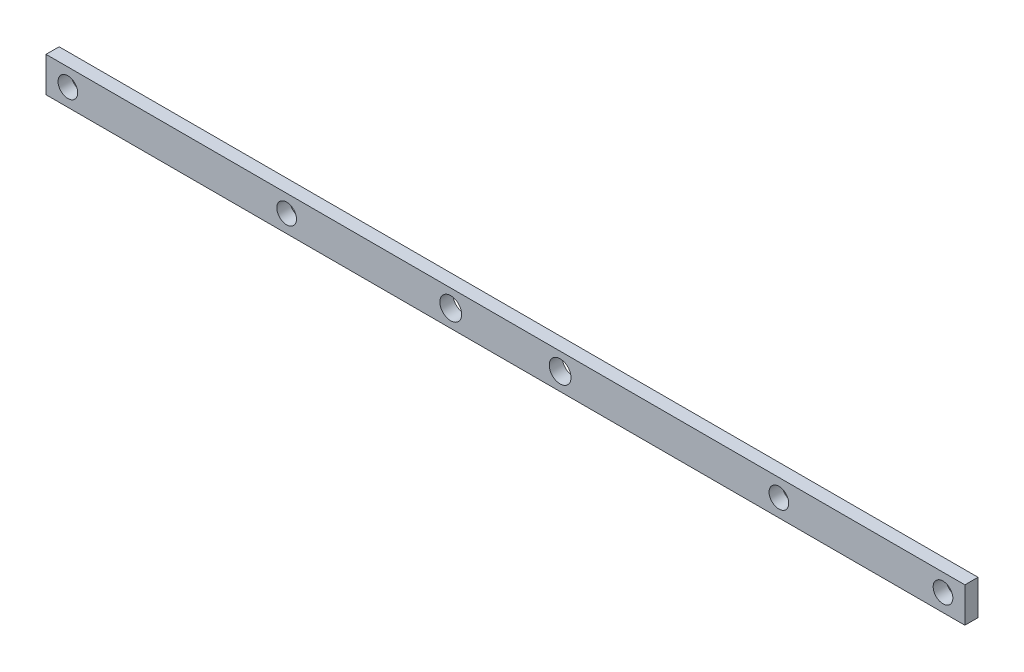
from build123d import *

# Parameters (mm, degrees)
SKETCH1_W           = 210
SKETCH1_H           = 8
SKETCH1_R           = 2.49
SKETCH1_R_2         = 2.25
BOSS_EXTRUDE1_DEPTH = 3


with BuildPart() as part:
    # Sketch1 → Boss-Extrude1 (new body)
    with BuildSketch(Plane.XY):
        Rectangle(SKETCH1_W, SKETCH1_H)
        with Locations((-12.5, 0)):
            Circle(SKETCH1_R, mode=Mode.SUBTRACT)
        with Locations((12.5, 0)):
            Circle(SKETCH1_R, mode=Mode.SUBTRACT)
        with Locations((-100, 0)):
            Circle(SKETCH1_R_2, mode=Mode.SUBTRACT)
        with Locations((100, 0)):
            Circle(SKETCH1_R_2, mode=Mode.SUBTRACT)
        with Locations((-50, 0)):
            Circle(SKETCH1_R_2, mode=Mode.SUBTRACT)
        with Locations((62.5, 0)):
            Circle(SKETCH1_R_2, mode=Mode.SUBTRACT)
    extrude(amount=BOSS_EXTRUDE1_DEPTH)


solid = part.part
